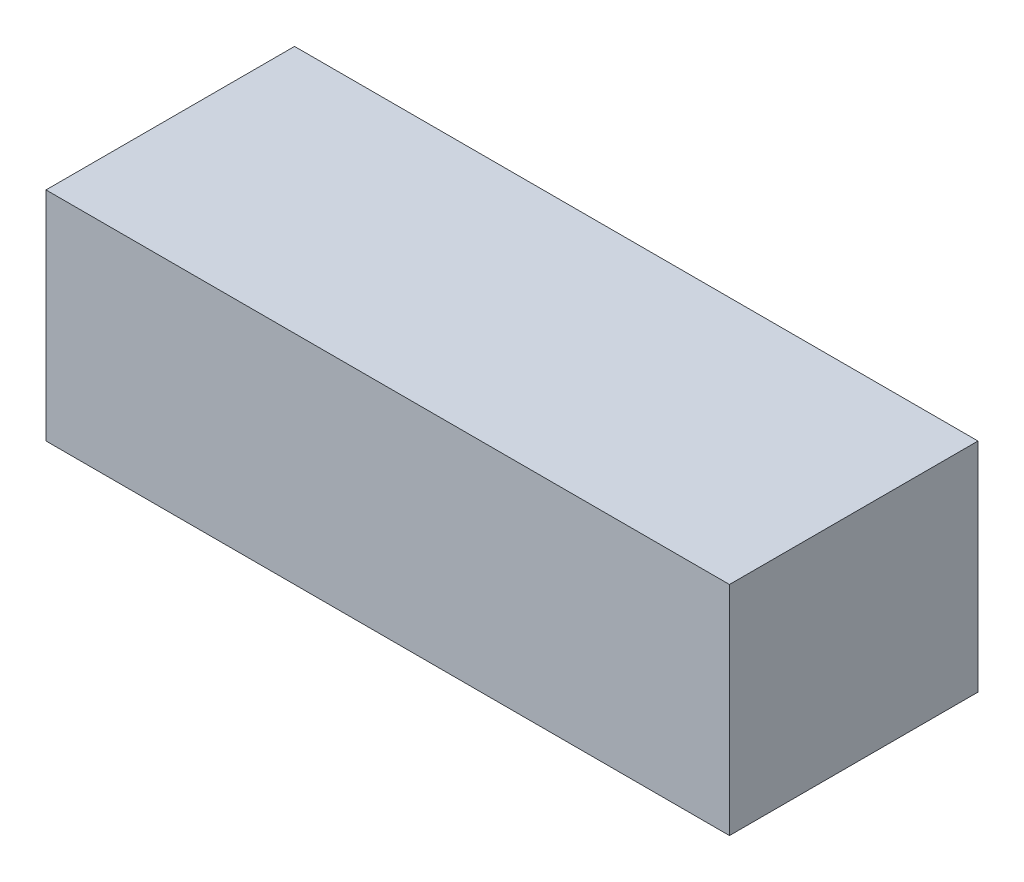
from build123d import *

# Parameters (mm, degrees)
SKETCH1_W           = 44
SKETCH1_H           = 16
BOSS_EXTRUDE1_DEPTH = 14


with BuildPart() as part:
    # Sketch1 → Boss-Extrude1 (new body)
    with BuildSketch(Plane(origin=(0, 0, 0), x_dir=(1, 0, 0), z_dir=(0, 1, 0))):
        Rectangle(SKETCH1_W, SKETCH1_H)
    extrude(amount=BOSS_EXTRUDE1_DEPTH)


solid = part.part
